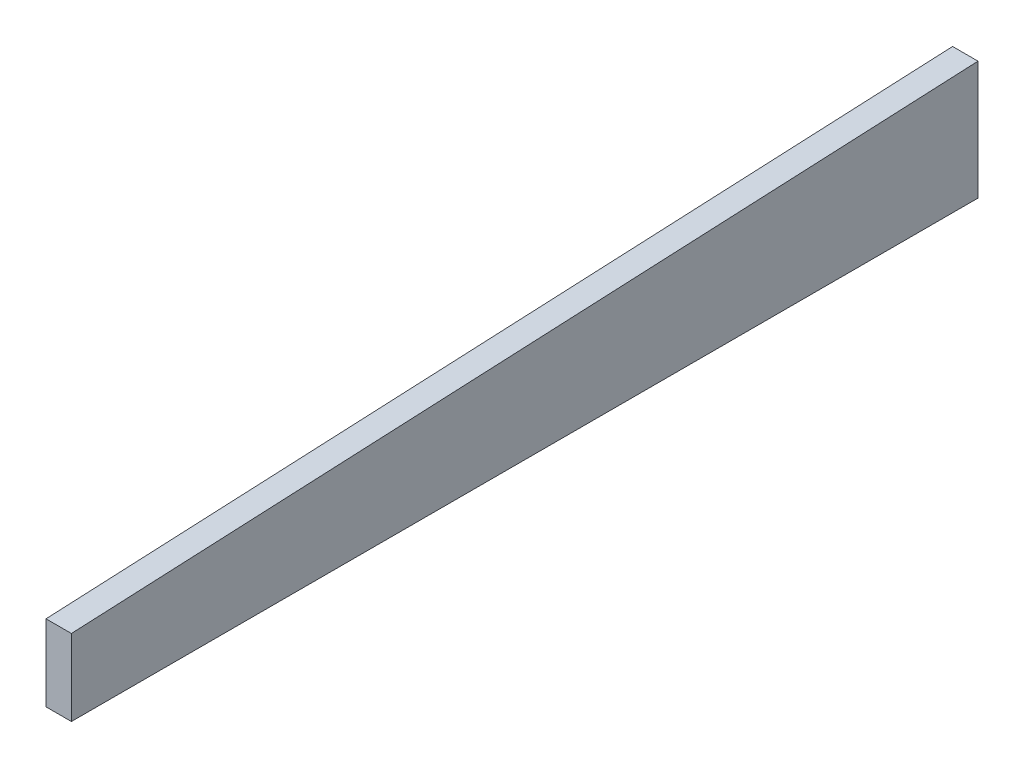
from build123d import *

# Parameters (mm, degrees)
EXTRUDE1_DEPTH = 19.05


with BuildPart() as part:
    # Sketch1 → Extrude1 (new body)
    with BuildSketch(Plane(origin=(0, 0, 0), x_dir=(0, 0, -1), z_dir=(1, 0, 0))):
        Polygon((-66.348427583, 29.636390306), (613.101572417, 61.386390306), (613.101572417, -27.513609694), (-66.348427583, -27.513609694), align=None)
    extrude(amount=EXTRUDE1_DEPTH)


solid = part.part
